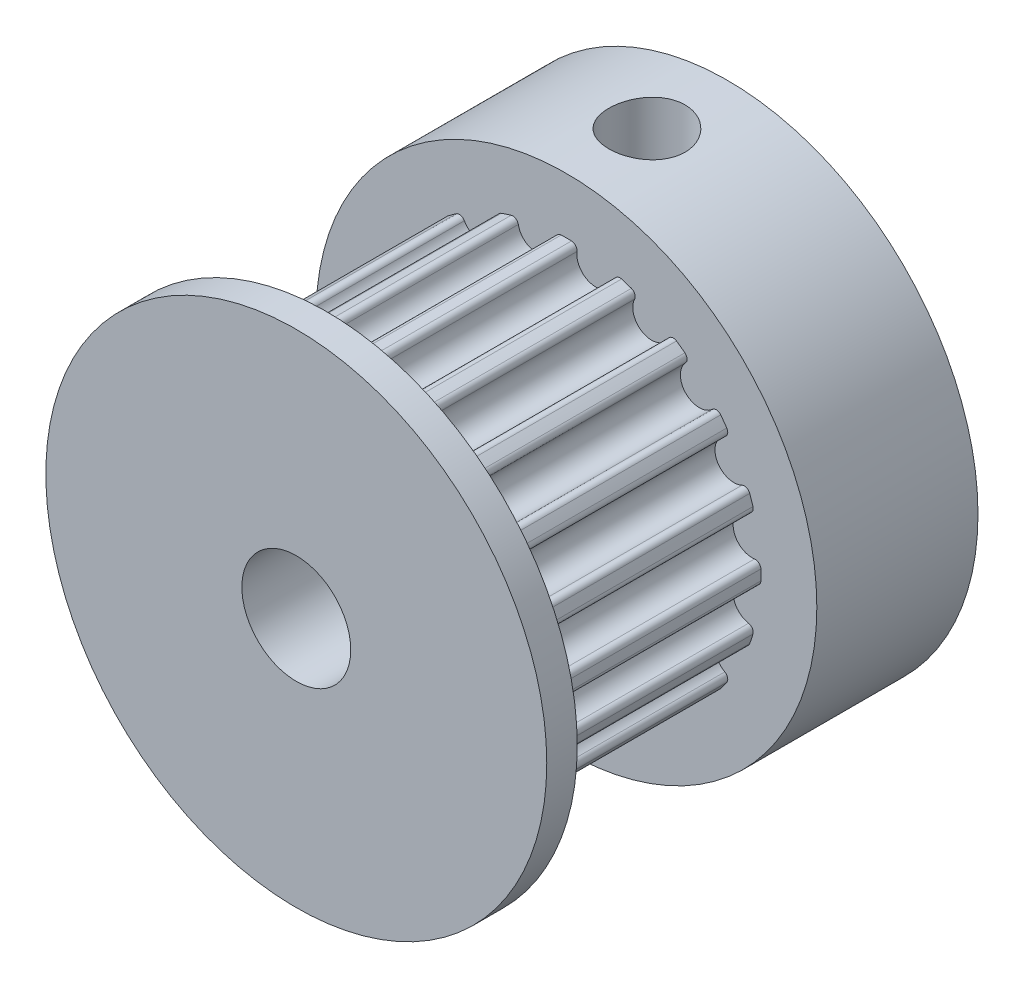
from build123d import *

# Parameters (mm, degrees)
BOSS_EXTRUDE1_DEPTH       = 11
FILLET2_R                 = 0.26
CIRPATTERN12_COUNT        = 20
FILLET2_OF_CIRPATTERN12_R = 0.26
SKETCH3_R                 = 2.5
SKETCH3_R_2               = 11.5
BOSS_EXTRUDE2_DEPTH       = 7.4
BOSS_EXTRUDE3_START       = 11
SKETCH3_3_R               = 2.5
SKETCH3_3_R_2             = 11.5
BOSS_EXTRUDE3_DEPTH       = 1.4
SKETCH3_4_R               = 2.5
CUT_EXTRUDE1_DEPTH        = 13.4
CUT_EXTRUDE1_DEPTH_BACK   = 8.4
CUT_EXTRUDE2_START        = -9.714643
SKETCH4_R                 = 1.75
CUT_EXTRUDE2_DEPTH        = 9.714643
CUT_EXTRUDE3_START        = -9.714643
SKETCH5_R                 = 1.75
CUT_EXTRUDE3_DEPTH        = 9.714643


with BuildPart() as part:
    # Sketch2 → Boss-Extrude1 (new body)
    with BuildSketch(Plane(origin=(0, 0, 0), x_dir=(0, 1, 0), z_dir=(0, 0, 1))):
        with BuildLine():
            ThreePointArc((2.211181489, 8.656346337), (2.487291524, 8.581085966), (2.760849478, 8.497020986))
            Line((2.760849478, 8.497020986), (0, 0))
            Line((0, 0), (0, 8.934296586))
            ThreePointArc((0, 8.934296586), (0.286146582, 8.929713076), (0.571999564, 8.915967249))
            ThreePointArc((0.571999564, 8.915967249), (1.214603583, 7.66870521), (2.211181489, 8.656346337))
        make_face()
    boss_extrude1 = extrude(amount=BOSS_EXTRUDE1_DEPTH)

    # Fillet2
    fillet2_edges = [part.edges().sort_by_distance(p)[0] for p in [
        (-8.915967249, 0.571999564, 5.5),
        (-8.656346337, 2.211181489, 5.5),
    ]]
    fillet(fillet2_edges, radius=FILLET2_R)

    # CirPattern12: Boss-Extrude1 ×20 about axis
    cirpattern12_axis = Axis((0, 0, 0), (0, 0, 1))
    for i in range(1, CIRPATTERN12_COUNT):
        add(boss_extrude1.rotate(cirpattern12_axis, i * 360 / CIRPATTERN12_COUNT))

    # Fillet2 of CirPattern12
    fillet2_of_cirpattern12_edges = [part.edges().sort_by_distance(p)[0] for p in [
        (-8.656346337, -2.211181489, 5.5),
        (-8.915967249, -0.571999564, 5.5),
        (-7.549381933, -4.777916691, 5.5),
        (-8.302831165, -3.299189314, 5.5),
        (-5.703431427, -6.876956117, 5.5),
        (-6.876956117, -5.703431427, 5.5),
        (-3.299189314, -8.302831165, 5.5),
        (-4.777916691, -7.549381933, 5.5),
        (-0.571999564, -8.915967249, 5.5),
        (-2.211181489, -8.656346337, 5.5),
        (2.211181489, -8.656346337, 5.5),
        (0.571999564, -8.915967249, 5.5),
        (4.777916691, -7.549381933, 5.5),
        (3.299189314, -8.302831165, 5.5),
        (6.876956117, -5.703431427, 5.5),
        (5.703431427, -6.876956117, 5.5),
        (8.302831165, -3.299189314, 5.5),
        (7.549381933, -4.777916691, 5.5),
        (8.915967249, -0.571999564, 5.5),
        (8.656346337, -2.211181489, 5.5),
        (8.656346337, 2.211181489, 5.5),
        (8.915967249, 0.571999564, 5.5),
        (7.549381933, 4.777916691, 5.5),
        (8.302831165, 3.299189314, 5.5),
        (5.703431427, 6.876956117, 5.5),
        (6.876956117, 5.703431427, 5.5),
        (3.299189314, 8.302831165, 5.5),
        (4.777916691, 7.549381933, 5.5),
        (0.571999564, 8.915967249, 5.5),
        (2.211181489, 8.656346337, 5.5),
        (-2.211181489, 8.656346337, 5.5),
        (-0.571999564, 8.915967249, 5.5),
        (-4.777916691, 7.549381933, 5.5),
        (-3.299189314, 8.302831165, 5.5),
        (-6.876956117, 5.703431427, 5.5),
        (-5.703431427, 6.876956117, 5.5),
        (-8.302831165, 3.299189314, 5.5),
        (-7.549381933, 4.777916691, 5.5),
    ]]
    fillet(fillet2_of_cirpattern12_edges, radius=FILLET2_OF_CIRPATTERN12_R)

    # Sketch3 → Boss-Extrude2 (add)
    with BuildSketch(Plane(origin=(0, 0, 0), x_dir=(0, 1, 0), z_dir=(0, 0, 1))):
        Circle(SKETCH3_R)
        Circle(SKETCH3_R_2)
        Circle(SKETCH3_R, mode=Mode.SUBTRACT)
    extrude(amount=-BOSS_EXTRUDE2_DEPTH)

    # Sketch3_3 → Boss-Extrude3 (add)
    with BuildSketch(Plane(origin=(0, 0, 0), x_dir=(0, 1, 0), z_dir=(0, 0, 1)).offset(BOSS_EXTRUDE3_START)):
        Circle(SKETCH3_3_R)
        Circle(SKETCH3_3_R_2)
        Circle(SKETCH3_3_R, mode=Mode.SUBTRACT)
    extrude(amount=BOSS_EXTRUDE3_DEPTH)

    # Sketch3_4 → Cut-Extrude1 (cut, two sides)
    with BuildSketch(Plane(origin=(0, 0, 0), x_dir=(0, 1, 0), z_dir=(0, 0, 1))) as cut_extrude1_sk:
        Circle(SKETCH3_4_R)
    extrude(amount=CUT_EXTRUDE1_DEPTH, mode=Mode.SUBTRACT)
    extrude(cut_extrude1_sk.sketch, amount=-CUT_EXTRUDE1_DEPTH_BACK, mode=Mode.SUBTRACT)

    # Sketch4 → Cut-Extrude2 (cut)
    with BuildSketch(Plane.ZY.offset(11.5).offset(CUT_EXTRUDE2_START)):
        with Locations((-3.7, 0)):
            Circle(SKETCH4_R)
    extrude(amount=CUT_EXTRUDE2_DEPTH, mode=Mode.SUBTRACT)

    # Sketch5 → Cut-Extrude3 (cut)
    with BuildSketch(Plane.ZX.offset(11.5).offset(CUT_EXTRUDE3_START)):
        with Locations((-3.7, 0)):
            Circle(SKETCH5_R)
    extrude(amount=CUT_EXTRUDE3_DEPTH, mode=Mode.SUBTRACT)


solid = part.part
